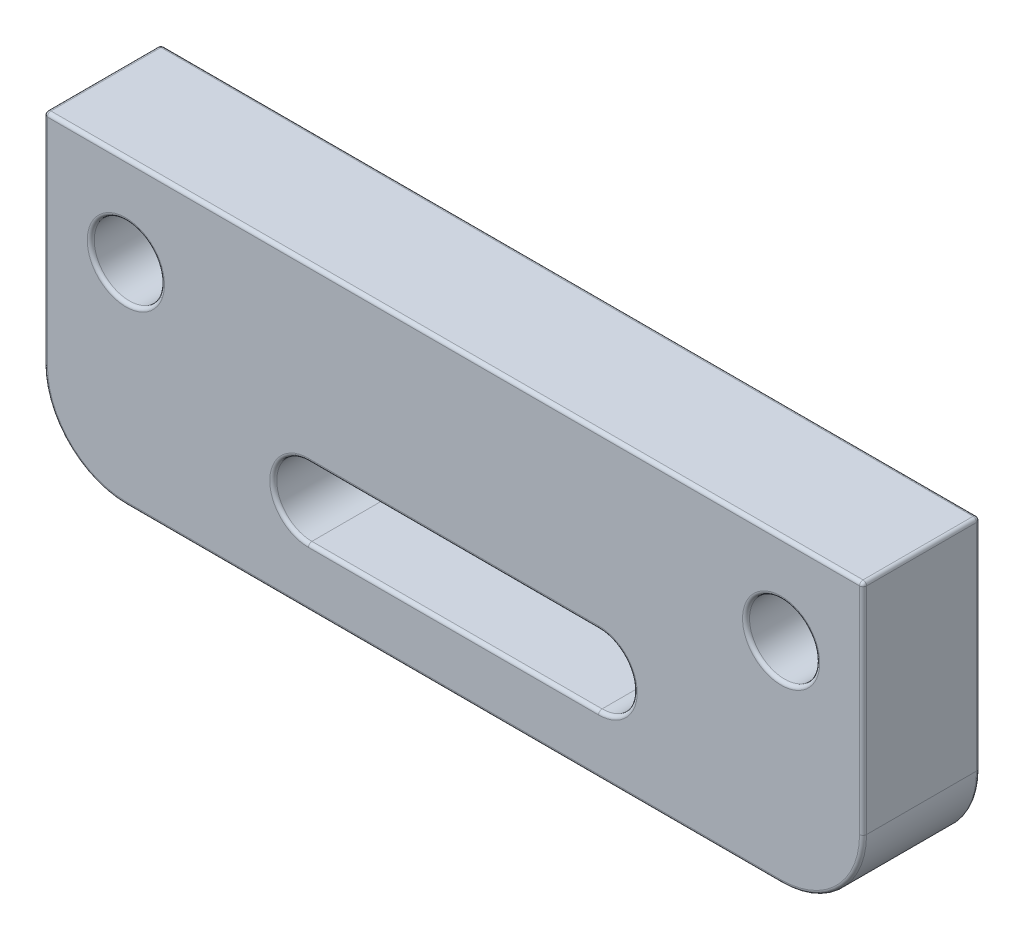
from build123d import *

# Parameters (mm, degrees)
SKETCH1_R               = 2
SKETCH1_W               = 35
SKETCH1_H               = 28
SKETCH1_R_2             = 1.5
SKETCH1_R_3             = 1
SKETCH1_W_2             = 23
SKETCH1_H_2             = 12
BOSS_EXTRUDE1_DEPTH     = 5
FILLET1_R               = 3.5
FILLET2_R               = 0.15
CUT_EXTRUDE1_DEPTH      = 1
CUT_EXTRUDE1_DEPTH_BACK = 6
FILLET3_R               = 0.15


with BuildPart() as part:
    # Sketch1 → Boss-Extrude1 (new body)
    with BuildSketch(Plane.XY):
        with BuildLine():
            ThreePointArc((-17.5, 9), (0, 26), (17.5, 9))
            Line((17.5, 9), (-17.5, 9))
        make_face()
        with Locations((-8.5, 16)):
            Circle(SKETCH1_R, mode=Mode.SUBTRACT)
        with Locations((8.5, 16)):
            Circle(SKETCH1_R, mode=Mode.SUBTRACT)
        with Locations((0, -5)):
            Rectangle(SKETCH1_W, SKETCH1_H)
        with Locations((14, -10)):
            Circle(SKETCH1_R_2, mode=Mode.SUBTRACT)
        with Locations((-14, 0)):
            Circle(SKETCH1_R_3, mode=Mode.SUBTRACT)
        with Locations((-14, -10)):
            Circle(SKETCH1_R_2, mode=Mode.SUBTRACT)
        with Locations((14, 0)):
            Circle(SKETCH1_R_3, mode=Mode.SUBTRACT)
        with BuildLine():
            ThreePointArc((6.2, -16.5), (7.7, -15), (6.2, -13.5))
            Line((6.2, -13.5), (-6.2, -13.5))
            ThreePointArc((-6.2, -13.5), (-7.7, -15), (-6.2, -16.5))
            Line((-6.2, -16.5), (6.2, -16.5))
        make_face(mode=Mode.SUBTRACT)
        Rectangle(SKETCH1_W_2, SKETCH1_H_2, mode=Mode.SUBTRACT)
    extrude(amount=BOSS_EXTRUDE1_DEPTH)

    # Fillet1
    fillet1_edges = [part.edges().sort_by_distance(p)[0] for p in [
        (17.5, -19, 2.5),
        (-17.5, -19, 2.5),
    ]]
    fillet(fillet1_edges, radius=FILLET1_R)

    # Fillet2
    fillet2_edges = [part.edges().sort_by_distance(p)[0] for p in [
        (0, 26, 5),
        (-17.5, -3.25, 5),
        (13, 0, 0),
        (-11.5, 0, 0),
        (0, -6, 0),
        (11.5, 0, 0),
        (0, 6, 0),
        (0, -13.5, 0),
        (-7.7, -15, 0),
        (0, -16.5, 0),
        (7.7, -15, 0),
        (-15.5, -10, 0),
        (-15, 0, 0),
        (12.5, -10, 0),
        (6.5, 16, 0),
        (17.5, -3.25, 5),
        (-10.5, 16, 0),
        (17.5, -3.25, 0),
        (-17.5, -3.25, 0),
        (0, 26, 0),
        (-10.5, 16, 5),
        (6.5, 16, 5),
        (12.5, -10, 5),
        (-15, 0, 5),
        (-15.5, -10, 5),
        (0, -19, 0),
        (0, -19, 5),
        (7.7, -15, 5),
        (16.474873734, -17.974873734, 0),
        (-16.474873734, -17.974873734, 0),
        (16.474873734, -17.974873734, 5),
        (-16.474873734, -17.974873734, 5),
        (0, -16.5, 5),
        (-7.7, -15, 5),
        (0, -13.5, 5),
        (0, 6, 5),
        (11.5, 0, 5),
        (0, -6, 5),
        (-11.5, 0, 5),
        (13, 0, 5),
    ]]
    fillet(fillet2_edges, radius=FILLET2_R)

    # Sketch2 → Cut-Extrude1 (cut, two sides)
    with BuildSketch(Plane.XY.offset(5)) as cut_extrude1_sk:
        Polygon((-143.203867772, -6.15), (-22.35, -6.15), (27.65, -6.15), (148.503867772, -6.15), (148.503867772, 235.557735544), (-143.203867772, 235.557735544), align=None)
    extrude(amount=CUT_EXTRUDE1_DEPTH, mode=Mode.SUBTRACT)
    extrude(cut_extrude1_sk.sketch, amount=-CUT_EXTRUDE1_DEPTH_BACK, mode=Mode.SUBTRACT)

    # Fillet3
    fillet3_edges = [part.edges().sort_by_distance(p)[0] for p in [
        (0, -6.15, 5),
        (17.456066017, -6.15, 4.956066017),
        (-17.456066017, -6.15, 0.043933983),
        (17.456066017, -6.15, 0.043933983),
        (17.5, -6.15, 2.5),
        (-17.456066017, -6.15, 4.956066017),
        (-17.5, -6.15, 2.5),
        (0, -6.15, 0),
    ]]
    fillet(fillet3_edges, radius=FILLET3_R)


solid = part.part
